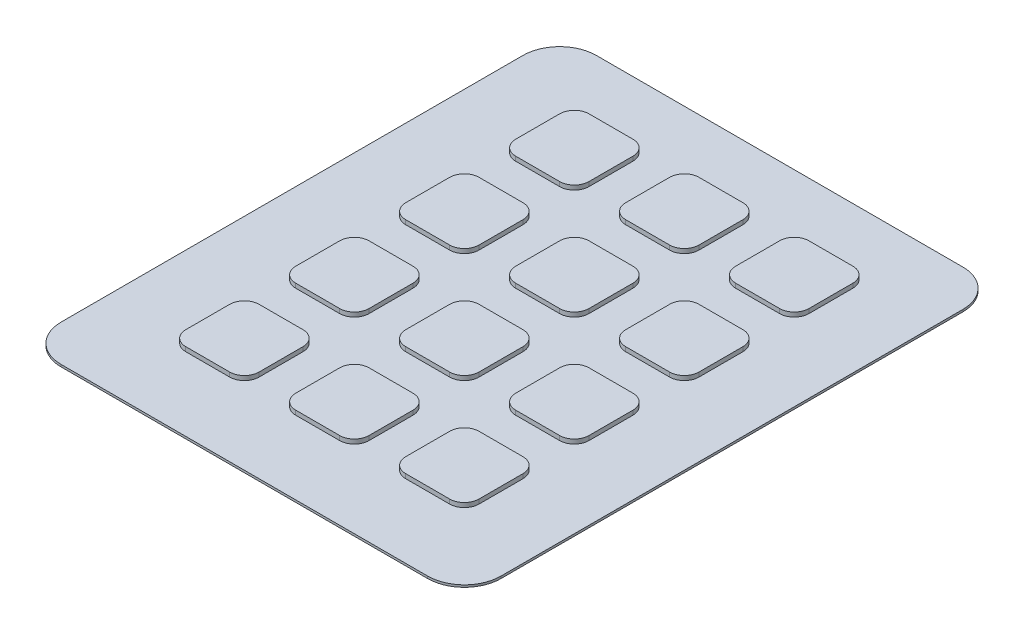
from build123d import *

# Parameters (mm, degrees)
SKETCH1_W              = 60
SKETCH1_H              = 73
BOSS_EXTRUDE1_DEPTH    = 0.3
FILLET1_R              = 5
SKETCH2_W              = 10
SKETCH2_H              = 10
BOSS_EXTRUDE2_DEPTH    = 0.6
FILLET2_R              = 2
LPATTERN1_COUNT        = 3
LPATTERN1_PITCH        = 15
LPATTERN1_COUNT_DIR2   = 4
LPATTERN1_PITCH_DIR2   = 15
FILLET2_OF_LPATTERN1_R = 2


with BuildPart() as part:
    # Sketch1 → Boss-Extrude1 (new body)
    with BuildSketch(Plane(origin=(0, 0, 0), x_dir=(1, 0, 0), z_dir=(0, 1, 0))):
        with Locations((-13.75, 5.339285714)):
            Rectangle(SKETCH1_W, SKETCH1_H)
    extrude(amount=BOSS_EXTRUDE1_DEPTH)

    # Fillet1
    fillet1_edges = [part.edges().sort_by_distance(p)[0] for p in [
        (-43.75, 0.15, -41.839285714),
        (16.25, 0.15, -41.839285714),
        (16.25, 0.15, 31.160714286),
        (-43.75, 0.15, 31.160714286),
    ]]
    fillet(fillet1_edges, radius=FILLET1_R)

    # Sketch2 → Boss-Extrude2 (add)
    with BuildSketch(Plane(origin=(0, 0.3, 0), x_dir=(1, 0, 0), z_dir=(0, 1, 0))):
        with Locations((1.25, -16.160714286)):
            Rectangle(SKETCH2_W, SKETCH2_H)
    boss_extrude2 = extrude(amount=BOSS_EXTRUDE2_DEPTH)

    # Fillet2
    fillet2_edges = [part.edges().sort_by_distance(p)[0] for p in [
        (6.25, 0.6, 21.160714286),
        (6.25, 0.6, 11.160714286),
        (-3.75, 0.6, 11.160714286),
        (-3.75, 0.6, 21.160714286),
    ]]
    fillet(fillet2_edges, radius=FILLET2_R)

    # LPattern1: Boss-Extrude2 3 × 4
    with Locations(*[(-i * LPATTERN1_PITCH, 0, -j * LPATTERN1_PITCH_DIR2) for i in range(LPATTERN1_COUNT) for j in range(LPATTERN1_COUNT_DIR2) if (i, j) != (0, 0)]):
        add(boss_extrude2)

    # Fillet2 of LPattern1
    fillet2_of_lpattern1_edges = [part.edges().sort_by_distance(p)[0] for p in [
        (6.25, 0.6, 6.160714286),
        (6.25, 0.6, -3.839285714),
        (-3.75, 0.6, -3.839285714),
        (-3.75, 0.6, 6.160714286),
        (6.25, 0.6, -8.839285714),
        (6.25, 0.6, -18.839285714),
        (-3.75, 0.6, -18.839285714),
        (-3.75, 0.6, -8.839285714),
        (6.25, 0.6, -23.839285714),
        (6.25, 0.6, -33.839285714),
        (-3.75, 0.6, -33.839285714),
        (-3.75, 0.6, -23.839285714),
        (-8.75, 0.6, 21.160714286),
        (-8.75, 0.6, 11.160714286),
        (-18.75, 0.6, 11.160714286),
        (-18.75, 0.6, 21.160714286),
        (-8.75, 0.6, 6.160714286),
        (-8.75, 0.6, -3.839285714),
        (-18.75, 0.6, -3.839285714),
        (-18.75, 0.6, 6.160714286),
        (-8.75, 0.6, -8.839285714),
        (-8.75, 0.6, -18.839285714),
        (-18.75, 0.6, -18.839285714),
        (-18.75, 0.6, -8.839285714),
        (-8.75, 0.6, -23.839285714),
        (-8.75, 0.6, -33.839285714),
        (-18.75, 0.6, -33.839285714),
        (-18.75, 0.6, -23.839285714),
        (-23.75, 0.6, 21.160714286),
        (-23.75, 0.6, 11.160714286),
        (-33.75, 0.6, 11.160714286),
        (-33.75, 0.6, 21.160714286),
        (-23.75, 0.6, 6.160714286),
        (-23.75, 0.6, -3.839285714),
        (-33.75, 0.6, -3.839285714),
        (-33.75, 0.6, 6.160714286),
        (-23.75, 0.6, -8.839285714),
        (-23.75, 0.6, -18.839285714),
        (-33.75, 0.6, -18.839285714),
        (-33.75, 0.6, -8.839285714),
        (-23.75, 0.6, -23.839285714),
        (-23.75, 0.6, -33.839285714),
        (-33.75, 0.6, -33.839285714),
        (-33.75, 0.6, -23.839285714),
    ]]
    fillet(fillet2_of_lpattern1_edges, radius=FILLET2_OF_LPATTERN1_R)


solid = part.part
